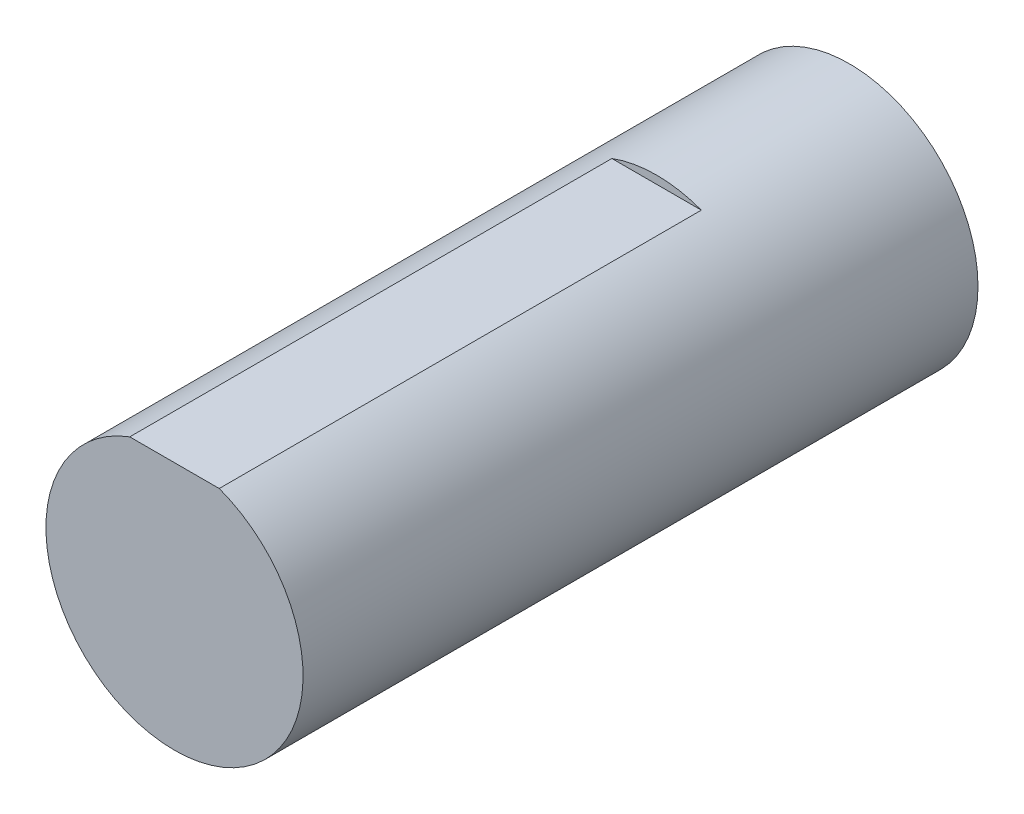
from build123d import *

# Parameters (mm, degrees)
SKETCH1_R               = 4
BOSS_EXTRUDE1_DEPTH     = 21
CUT_EXTRUDE1_DEPTH      = 1
CUT_EXTRUDE1_DEPTH_BACK = 15


with BuildPart() as part:
    # Sketch1 → Boss-Extrude1 (new body)
    with BuildSketch(Plane.XY):
        Circle(SKETCH1_R)
    extrude(amount=BOSS_EXTRUDE1_DEPTH)

    # Sketch2 → Cut-Extrude1 (cut, two sides)
    with BuildSketch(Plane.XY.offset(21)) as cut_extrude1_sk:
        Polygon((-30.274263906, 3.75), (-1.391941091, 3.75), (1.391941091, 3.75), (30.274263906, 3.75), (30.274263906, 61.514645631), (-30.274263906, 61.514645631), align=None)
    extrude(amount=CUT_EXTRUDE1_DEPTH, mode=Mode.SUBTRACT)
    extrude(cut_extrude1_sk.sketch, amount=-CUT_EXTRUDE1_DEPTH_BACK, mode=Mode.SUBTRACT)


solid = part.part
